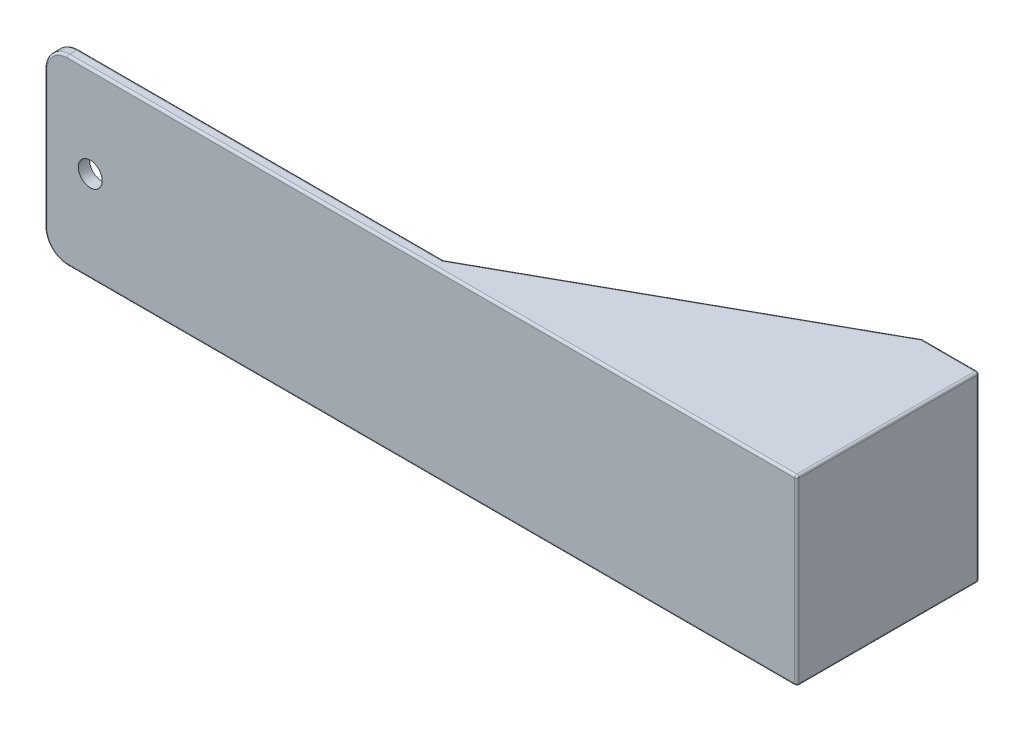
from build123d import *

# Parameters (mm, degrees)
SKETCH_1_W          = 330
SKETCH_1_H          = 80
EXTRUDE_1_DEPTH     = 5
SKETCH_2_R          = 5.25
CUT_EXTRUDE_1_DEPTH = 5
SKETCH_3_R          = 4
CUT_EXTRUDE_2_DEPTH = 10
FILLET_1_R          = 10
SKETCH_13_R         = 6.969385005
EXTRUDE_5_DEPTH     = 5
SKETCH_14_W         = 5
SKETCH_14_H         = 75
EXTRUDE_6_DEPTH     = 80
SKETCH_15_W         = 20
SKETCH_15_H         = 5
EXTRUDE_7_DEPTH     = 80
EXTRUDE_8_DEPTH     = 5
SKETCH_17_R         = 3
CUT_EXTRUDE_5_DEPTH = 5
FILLET_2_R          = 1


with BuildPart() as part:
    # 草图1 → 凸台-拉伸1 (new body)
    with BuildSketch(Plane.XY):
        Rectangle(SKETCH_1_W, SKETCH_1_H)
    extrude(amount=EXTRUDE_1_DEPTH)

    # 草图2 → 切除-拉伸1 (cut)
    with BuildSketch(Plane.XY.offset(5)):
        with Locations((-145, 0)):
            Circle(SKETCH_2_R)
    extrude(amount=-CUT_EXTRUDE_1_DEPTH, mode=Mode.SUBTRACT)

    # 草图3 → 切除-拉伸2 (cut)
    with BuildSketch(Plane.XY.offset(5)):
        with Locations((-45, 0)):
            Circle(SKETCH_3_R)
    extrude(amount=-CUT_EXTRUDE_2_DEPTH, mode=Mode.SUBTRACT)

    # 圆角1
    fillet_1_edges = [part.edges().sort_by_distance(p)[0] for p in [
        (-165, 40, 2.5),
        (-165, -40, 2.5),
    ]]
    fillet(fillet_1_edges, radius=FILLET_1_R)

    # 草图13 → 凸台-拉伸5 (add)
    with BuildSketch(Plane.XY.offset(5)):
        with Locations((-45, 0)):
            Circle(SKETCH_13_R)
    extrude(amount=-EXTRUDE_5_DEPTH)

    # 草图14 → 凸台-拉伸6 (add)
    with BuildSketch(Plane.XZ.offset(40)):
        with Locations((162.5, -37.5)):
            Rectangle(SKETCH_14_W, SKETCH_14_H)
    extrude(amount=-EXTRUDE_6_DEPTH)

    # 草图15 → 凸台-拉伸7 (add)
    with BuildSketch(Plane.XZ.offset(40)):
        with Locations((150, -72.5)):
            Rectangle(SKETCH_15_W, SKETCH_15_H)
    extrude(amount=-EXTRUDE_7_DEPTH)

    # 草图16 → 凸台-拉伸8 (add)
    with BuildSketch(Plane.XZ.offset(40)):
        Polygon((5, 5), (5, 0), (140, -75), (165, -75), (165, 5), align=None)
    extrude_8 = extrude(amount=-EXTRUDE_8_DEPTH)

    # 镜向1: 凸台-拉伸8 across plane
    add(extrude_8.mirror(Plane.ZX))

    # 草图17 → 切除-拉伸5 (cut)
    with BuildSketch(Plane(origin=(0, 0, -75), x_dir=(-1, 0, 0), z_dir=(0, 0, -1))):
        with Locations((-152, -15)):
            Circle(SKETCH_17_R)
        with Locations((-152, 15)):
            Circle(SKETCH_17_R)
    extrude(amount=-CUT_EXTRUDE_5_DEPTH, mode=Mode.SUBTRACT)

    # 圆角2
    fillet_2_edges = [part.edges().sort_by_distance(p)[0] for p in [
        (72.5, 40, -37.5),
        (72.5, 35, -37.5),
        (165, 0, 5),
        (5, 40, 5),
        (-75, -40, 0),
        (5, -40, 5),
        (-165, 0, 0),
        (-162.071067812, 37.071067812, 0),
        (-162.071067812, -37.071067812, 0),
        (-165, 0, 5),
        (-162.071067812, 37.071067812, 5),
        (-162.071067812, -37.071067812, 5),
        (165, 0, -75),
        (152.5, -40, -75),
        (152.5, 40, -75),
        (72.5, -40, -37.5),
        (72.5, -35, -37.5),
        (165, 40, -35),
        (165, -40, -35),
        (-75, 40, 0),
    ]]
    fillet(fillet_2_edges, radius=FILLET_2_R)


solid = part.part
